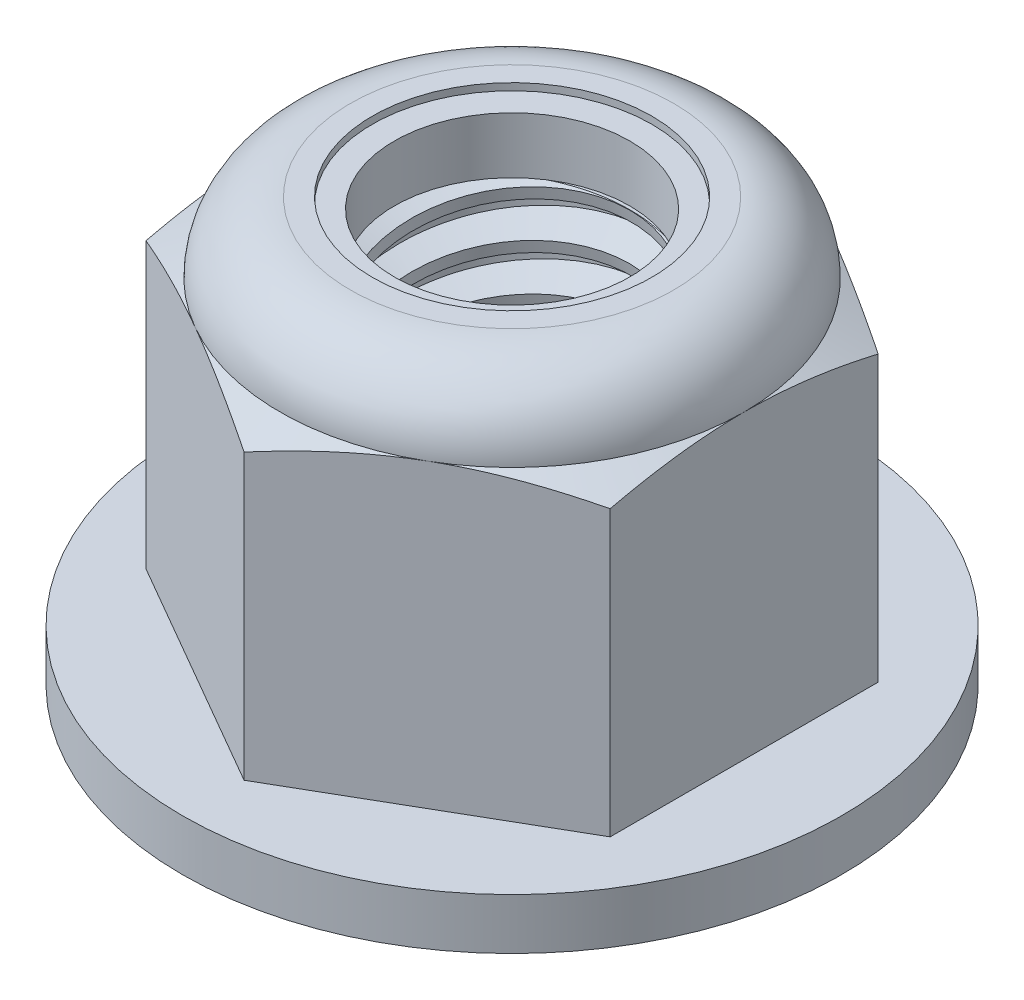
from build123d import *

# Parameters (mm, degrees)
EXTRUDE1_DEPTH      = 9.1
SKETCH8_W           = 7.1
SKETCH8_H           = 1.1
SKETCH2_W           = 3
SKETCH2_H           = 9.1
LPATTERN1_COUNT     = 9
LPATTERN1_PITCH     = 1
LPATTERN1_COL_COUNT = 2
LPATTERN1_COL_PITCH = 1


with BuildPart() as part:
    # Sketch1 → Extrude1 (new body)
    with BuildSketch(Plane(origin=(0, 0, 0), x_dir=(1, 0, 0), z_dir=(0, 1, 0))):
        Polygon((0, 5.773502692), (-5, 2.886751346), (-5, -2.886751346), (0, -5.773502692), (5, -2.886751346), (5, 2.886751346), align=None)
    extrude(amount=EXTRUDE1_DEPTH)

    # Sketch8 → Revolve3 (revolve)
    with BuildSketch(Plane(origin=(0, 0, 0), x_dir=(0, 0, -1), z_dir=(1, 0, 0))):
        with Locations((3.55, 0.55)):
            Rectangle(SKETCH8_W, SKETCH8_H)
    revolve(axis=Axis((0, 0, 0), (0, -1, 0)))

    # Sketch4 → Cut-Revolve2 (revolve, cut)
    with BuildSketch(Plane(origin=(0, 0, 0), x_dir=(0, 0, -1), z_dir=(1, 0, 0))):
        Polygon((0, 9.1), (3, 9.1), (2.538023184, 8.884576673), (2.538023184, 0.215423327), (3, 0), (0, 0), align=None)
    revolve(axis=Axis((0, 9.1, 0), (0, 1, 0)), mode=Mode.SUBTRACT)


with BuildPart() as body_2:
    # Sketch2 → Revolve1 (revolve)
    with BuildSketch(Plane(origin=(0, 0, 0), x_dir=(0, 0, -1), z_dir=(1, 0, 0))):
        with Locations((1.5, 4.55)):
            Rectangle(SKETCH2_W, SKETCH2_H)
    revolve(axis=Axis((0, -3, 0), (0, 1, 0)))

    # Sketch3 → Cut-Revolve1 (revolve, cut)
    with BuildSketch(Plane(origin=(0, 0, 0), x_dir=(0, 0, -1), z_dir=(1, 0, 0))):
        Polygon((3.020549873, 8.97670076), (3.164398987, 8.113606076), (2.579122931, 8.332870615), (2.538023184, 8.579469096), align=None)
    cut_revolve1 = revolve(axis=Axis((0, 9.1, 0.178376498), (0, -0.986393924, -0.164398987)), mode=Mode.SUBTRACT)

    # LPattern1: Cut-Revolve1 ×9
    with Locations(*[(0, -i * LPATTERN1_PITCH, 0) for i in range(1, LPATTERN1_COUNT)]):
        add(cut_revolve1, mode=Mode.SUBTRACT)

    # LPattern1 col: Cut-Revolve1 ×2
    with Locations(*[(0, i * LPATTERN1_COL_PITCH, 0) for i in range(1, LPATTERN1_COL_COUNT)]):
        add(cut_revolve1, mode=Mode.SUBTRACT)


with BuildPart() as part_1:
    add(part.part)

    # Combine1: cut body 2
    add(body_2.part, mode=Mode.SUBTRACT)

    # Sketch5 → Cut-Revolve3 (revolve, cut)
    with BuildSketch(Plane(origin=(0, 0, 0), x_dir=(0, 0, -1), z_dir=(1, 0, 0))):
        with BuildLine():
            Line((5.773502692, 1.1), (5.773502692, 7.222643104))
            Line((5.773502692, 7.222643104), (5, 7.583333333))
            ThreePointArc((5, 7.583333333), (4.555778618, 8.655778618), (3.483333333, 9.1))
            Line((3.483333333, 9.1), (3.483333333, 10.37))
            Line((3.483333333, 10.37), (7.043502692, 10.37))
            Line((7.043502692, 10.37), (7.043502692, 1.1))
            Line((7.043502692, 1.1), (5.773502692, 1.1))
        make_face()
    revolve(axis=Axis((0, 0, 0), (0, 1, 0)), mode=Mode.SUBTRACT)

    # Sketch6 → Cut-Revolve4 (revolve, cut)
    with BuildSketch(Plane(origin=(0, 0, 0), x_dir=(0, 0, -1), z_dir=(1, 0, 0))):
        with BuildLine():
            Line((0, 7.583333333), (4.8476, 7.583333333))
            ThreePointArc((4.8476, 7.583333333), (4.448015545, 8.548015545), (3.483333333, 8.9476))
            Line((3.483333333, 8.9476), (3.010678259, 8.9476))
            Line((3.010678259, 8.9476), (3.010678259, 10.37))
            Line((3.010678259, 10.37), (0, 10.37))
            Line((0, 10.37), (0, 7.583333333))
        make_face()
    revolve(axis=Axis((0, 10.37, 0), (0, 1, 0)), mode=Mode.SUBTRACT)


with BuildPart() as body_2_2:
    # Sketch7 → Revolve2 (revolve)
    with BuildSketch(Plane(origin=(0, 0, 0), x_dir=(0, 0, -1), z_dir=(1, 0, 0))):
        with BuildLine():
            Line((2.538023184, 7.659533333), (4.769144088, 7.659533333))
            ThreePointArc((4.769144088, 7.659533333), (4.366782556, 8.5206877), (3.483333333, 8.8714))
            Line((3.483333333, 8.8714), (2.538023184, 8.8714))
            Line((2.538023184, 8.8714), (2.538023184, 7.659533333))
        make_face()
    revolve(axis=Axis((0, 7.659533333, 0), (0, 1, 0)))


solid = Compound([part_1.part, body_2_2.part])
